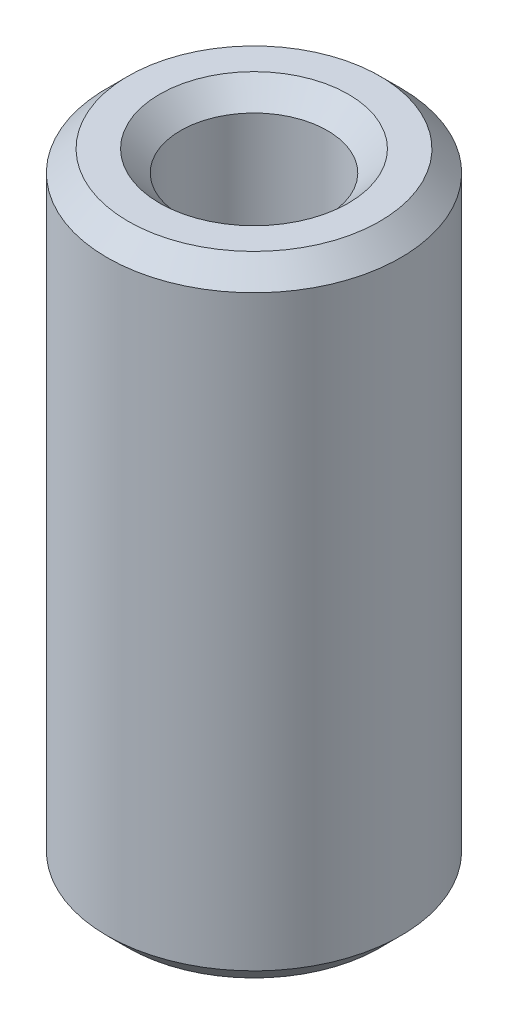
from build123d import *

# Parameters (mm, degrees)
SKETCH1_R           = 3.5
SKETCH1_R_2         = 1.75
BOSS_EXTRUDE1_DEPTH = 15
CHAMFER1_SIZE       = 0.5


with BuildPart() as part:
    # Sketch1 → Boss-Extrude1 (new body)
    with BuildSketch(Plane(origin=(0, 0, 0), x_dir=(1, 0, 0), z_dir=(0, 1, 0))):
        Circle(SKETCH1_R)
        Circle(SKETCH1_R_2, mode=Mode.SUBTRACT)
    extrude(amount=BOSS_EXTRUDE1_DEPTH)

    # Chamfer1
    chamfer1_edges = [part.edges().sort_by_distance(p)[0] for p in [
        (-3.5, 0, 0),
        (-3.5, 15, 0),
        (-1.75, 0, 0),
        (-1.75, 15, 0),
    ]]
    chamfer(chamfer1_edges, length=CHAMFER1_SIZE)


solid = part.part
